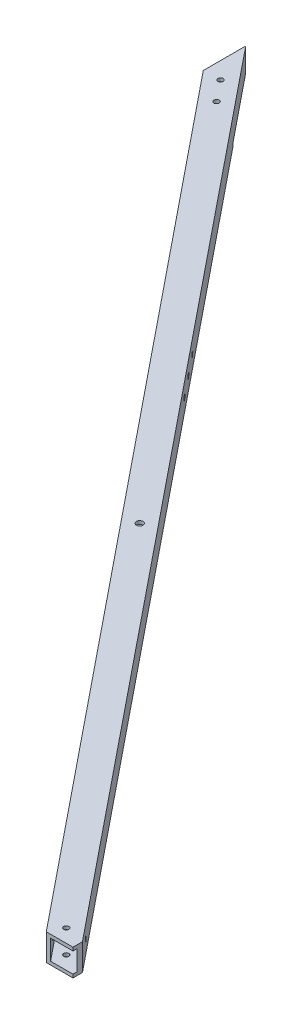
from build123d import *

# Parameters (mm, degrees)
BOSS_EXTRUDE1_DEPTH      = 25.4
SKETCH2_W                = 19.05
SKETCH2_H                = 19.05
CUT_EXTRUDE1_DEPTH       = 1062.13626679
CUT_EXTRUDE4_DEPTH       = 26.4
SKETCH4_R                = 2.5019
SKETCH4_R_2              = 2.4892
CUT_EXTRUDE5_DEPTH       = 26.4
SKETCH6_R                = 2.4892
CUT_EXTRUDE7_DEPTH       = 539.684978519
SKETCH7_R                = 3.175
CUT_EXTRUDE8_DEPTH       = 26.4
CUT_EXTRUDE14_DEPTH      = 3.175
SKETCH16_R               = 2.4892
CUT_EXTRUDE15_DEPTH      = 23.225
CUT_EXTRUDE15_DEPTH_BACK = 4.175
SKETCH17_R               = 2.4892
CUT_EXTRUDE16_DEPTH      = 519.943248576


with BuildPart() as part:
    # Sketch1 → Boss-Extrude1 (new body)
    with BuildSketch(Plane(origin=(0, 0, 0), x_dir=(1, 0, 0), z_dir=(0, 1, 0))):
        Polygon((-584.2, 762), (-584.2, 721.632068306), (0, 0), (0, 40.367931694), align=None)
        Polygon((0, 40.367931694), (32.680013447, 0), (0, 0), align=None)
        Polygon((-635, 824.750614635), (-584.2, 762), (-584.2, 721.632068306), (-635, 784.382682941), align=None)
    extrude(amount=BOSS_EXTRUDE1_DEPTH)

    # Sketch2 → Cut-Extrude1 (cut, through all)
    with BuildSketch(Plane(origin=(12.938283504, 0, 15.981992956), x_dir=(0, -1, 0), z_dir=(0.629212321, 0, 0.777233462))):
        with Locations((-12.7, 12.7)):
            Rectangle(SKETCH2_W, SKETCH2_H)
    extrude(amount=-CUT_EXTRUDE1_DEPTH, mode=Mode.SUBTRACT)

    # Sketch3 → Cut-Extrude4 (cut, through all)
    with BuildSketch(Plane(origin=(0, 25.4, 0), x_dir=(1, 0, 0), z_dir=(0, 1, 0))):
        Polygon((25.4, 8.992624377), (25.4, 0), (32.680013447, 0), align=None)
    extrude(amount=-CUT_EXTRUDE4_DEPTH, mode=Mode.SUBTRACT)

    # Sketch4 → Cut-Extrude5 (cut, through all)
    with BuildSketch(Plane.XZ):
        with Locations((-571.537427097, -1019.306313169)):
            Circle(SKETCH4_R)
        with Locations((-565.206140645, -1008.297007475)):
            Circle(SKETCH4_R)
        with Locations((6.35, -12.7)):
            Circle(SKETCH4_R_2)
    extrude(amount=-CUT_EXTRUDE5_DEPTH, mode=Mode.SUBTRACT)

    # Sketch6 → Cut-Extrude7 (cut, through all)
    with BuildSketch(Plane(origin=(0, 0, 0), x_dir=(0.629212321, 0, 0.777233462), z_dir=(-0.777233462, 0, 0.629212321))):
        with Locations((-12.7, 12.7)):
            Circle(SKETCH6_R)
    extrude(amount=-CUT_EXTRUDE7_DEPTH, mode=Mode.SUBTRACT)

    # Sketch7 → Cut-Extrude8 (cut, through all)
    with BuildSketch(Plane(origin=(0, 25.4, 0), x_dir=(1, 0, 0), z_dir=(0, 1, 0))):
        with Locations((-292.1, 381)):
            Circle(SKETCH7_R)
    extrude(amount=-CUT_EXTRUDE8_DEPTH, mode=Mode.SUBTRACT)

    # Sketch15 → Cut-Extrude14 (cut)
    with BuildSketch(Plane.XZ):
        Polygon((-635, -784.382682941), (-635, -824.750614635), (-584.2, -762), (-584.2, -721.632068306), align=None)
    extrude(amount=-CUT_EXTRUDE14_DEPTH, mode=Mode.SUBTRACT)

    # Sketch16 → Cut-Extrude15 (cut, two sides)
    with BuildSketch(Plane.XZ.offset(-22.225)) as cut_extrude15_sk:
        with Locations((-603.036014087, -765.083188902)):
            Circle(SKETCH16_R)
        with Locations((-619.018007044, -784.824918845)):
            Circle(SKETCH16_R)
    extrude(amount=CUT_EXTRUDE15_DEPTH, mode=Mode.SUBTRACT)
    extrude(cut_extrude15_sk.sketch, amount=-CUT_EXTRUDE15_DEPTH_BACK, mode=Mode.SUBTRACT)

    # Sketch17 → Cut-Extrude16 (cut, through all)
    with BuildSketch(Plane(origin=(19.741729943, 0, -15.981992956), x_dir=(-0.629212321, 0, -0.777233462), z_dir=(0.777233462, 0, -0.629212321))):
        with Locations((697.673599675, 12.7)):
            Circle(SKETCH17_R)
        with Locations((672.273599675, 12.7)):
            Circle(SKETCH17_R)
        with Locations((646.873599675, 12.7)):
            Circle(SKETCH17_R)
    extrude(amount=-CUT_EXTRUDE16_DEPTH, mode=Mode.SUBTRACT)


solid = part.part
